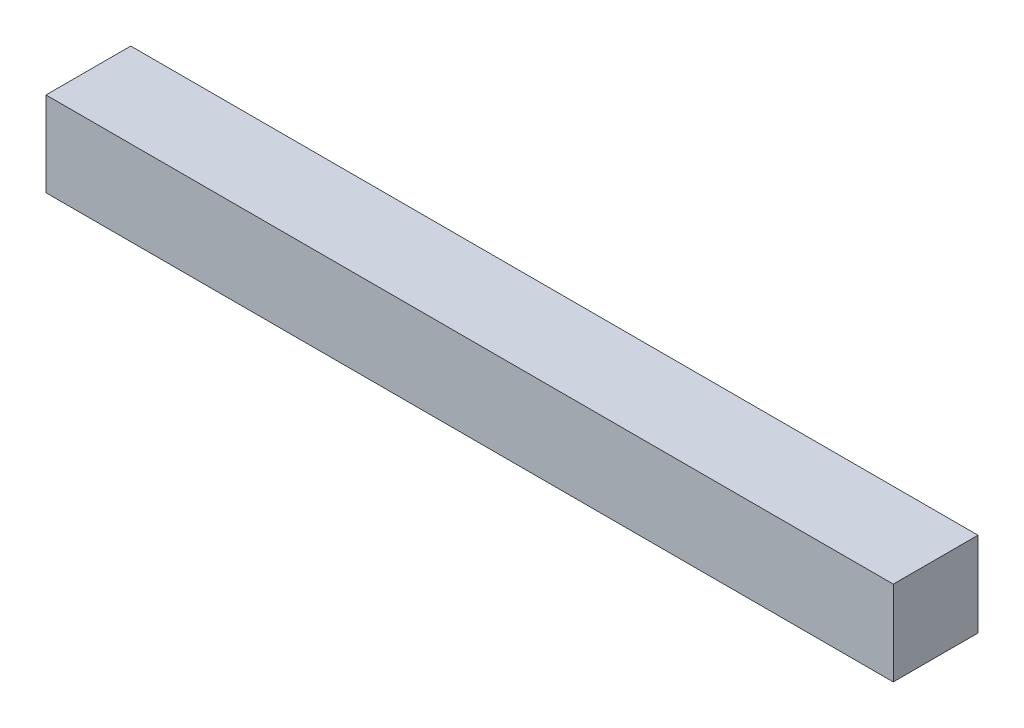
from build123d import *

# Parameters (mm, degrees)
CROQUIS1_W              = 30
CROQUIS1_H              = 30
SALIENTE_EXTRUIR1_DEPTH = 150


with BuildPart() as part:
    # Croquis1 → Saliente-Extruir1 (new body, symmetric)
    with BuildSketch(Plane(origin=(0, 0, 0), x_dir=(0, 0, -1), z_dir=(1, 0, 0))):
        Rectangle(CROQUIS1_W, CROQUIS1_H)
    extrude(amount=SALIENTE_EXTRUIR1_DEPTH, both=True)


solid = part.part
